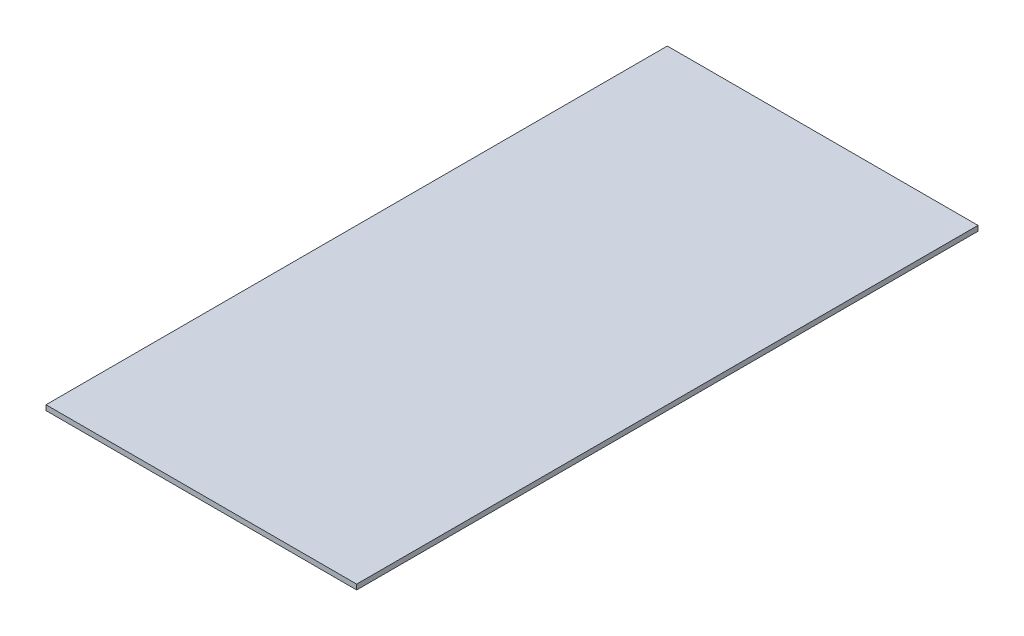
from build123d import *

# Parameters (mm, degrees)
SKETCH1_W           = 609.6
SKETCH1_H           = 1219.2
BOSS_EXTRUDE1_DEPTH = 10


with BuildPart() as part:
    # Sketch1 → Boss-Extrude1 (new body)
    with BuildSketch(Plane(origin=(0, 0, 0), x_dir=(1, 0, 0), z_dir=(0, 1, 0))):
        with Locations((-277.230150754, 19.401005025)):
            Rectangle(SKETCH1_W, SKETCH1_H)
    extrude(amount=BOSS_EXTRUDE1_DEPTH)


solid = part.part
